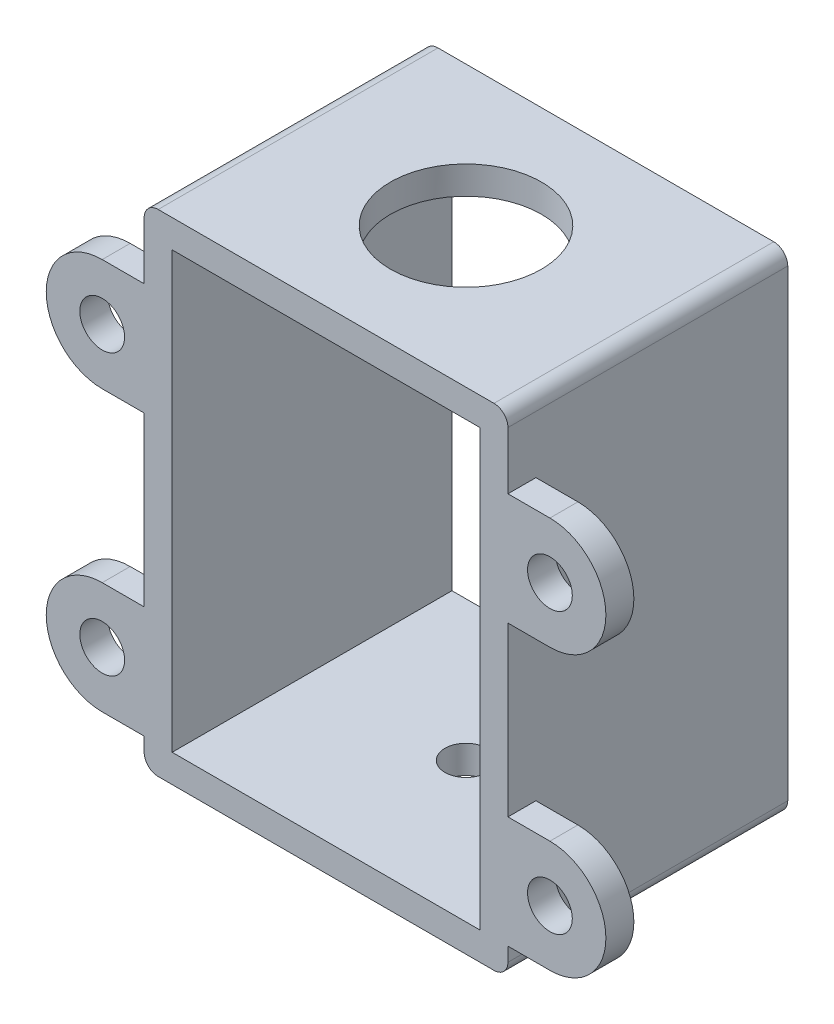
from build123d import *

# Parameters (mm, degrees)
SKETCH1_W           = 22
SKETCH1_H           = 31.5
BOSS_EXTRUDE1_DEPTH = 20
SKETCH2_R           = 5.4
CUT_EXTRUDE1_DEPTH  = 20
SKETCH3_R           = 1.5
CUT_EXTRUDE2_DEPTH  = 20
SKETCH4_W           = 22
SKETCH4_H           = 20
SKETCH4_R           = 1.5
BOSS_EXTRUDE2_DEPTH = 0.4
SKETCH5_R           = 44.087047381
CUT_EXTRUDE3_DEPTH  = 0.4
FILLET2_R           = 1
SKETCH6_R           = 1.6
BOSS_EXTRUDE3_DEPTH = 2


with BuildPart() as part:
    # Sketch1 → Boss-Extrude1 (new body)
    with BuildSketch(Plane.XY):
        Polygon((22, 2), (24, 2), (24, -33.5), (-2, -33.5), (-2, 2), align=None)
        with Locations((11, -15.75)):
            Rectangle(SKETCH1_W, SKETCH1_H, mode=Mode.SUBTRACT)
    extrude(amount=BOSS_EXTRUDE1_DEPTH)

    # Sketch2 → Cut-Extrude1 (cut)
    with BuildSketch(Plane(origin=(0, 2, 0), x_dir=(1, 0, 0), z_dir=(0, 1, 0))):
        with Locations((11, -10)):
            Circle(SKETCH2_R)
    extrude(amount=-CUT_EXTRUDE1_DEPTH, mode=Mode.SUBTRACT)

    # Sketch3 → Cut-Extrude2 (cut)
    with BuildSketch(Plane(origin=(0, -33.5, 0), x_dir=(-1, 0, 0), z_dir=(0, -1, 0))):
        with Locations((-11, -10)):
            Circle(SKETCH3_R)
    extrude(amount=-CUT_EXTRUDE2_DEPTH, mode=Mode.SUBTRACT)

    # Sketch4 → Boss-Extrude2 (add)
    with BuildSketch(Plane(origin=(0, -31.5, 0), x_dir=(1, 0, 0), z_dir=(0, 1, 0))):
        with Locations((11, -10)):
            Rectangle(SKETCH4_W, SKETCH4_H)
        with Locations((11, -10)):
            Circle(SKETCH4_R, mode=Mode.SUBTRACT)
    extrude(amount=BOSS_EXTRUDE2_DEPTH)

    # Sketch5 → Cut-Extrude3 (cut)
    with BuildSketch(Plane(origin=(0, -33.5, 0), x_dir=(-1, 0, 0), z_dir=(0, -1, 0))):
        with Locations((-11, -10)):
            Circle(SKETCH5_R)
    extrude(amount=-CUT_EXTRUDE3_DEPTH, mode=Mode.SUBTRACT)

    # Fillet2
    fillet2_edges = [part.edges().sort_by_distance(p)[0] for p in [
        (24, -33.1, 10),
        (-2, -33.1, 10),
        (-2, 2, 10),
        (24, 2, 10),
    ]]
    fillet(fillet2_edges, radius=FILLET2_R)

    # Sketch6 → Boss-Extrude3 (add)
    with BuildSketch(Plane.XY.offset(20)):
        with BuildLine():
            Line((22, -31.1), (27, -31.1))
            ThreePointArc((27, -31.1), (31, -27.1), (27, -23.1))
            Line((27, -23.1), (22, -23.1))
            Line((22, -23.1), (22, -31.1))
        make_face()
        with Locations((27, -27.1)):
            Circle(SKETCH6_R, mode=Mode.SUBTRACT)
        with BuildLine():
            Line((27, -11.1), (22, -11.1))
            Line((22, -11.1), (22, -3.1))
            Line((22, -3.1), (27, -3.1))
            ThreePointArc((27, -3.1), (31, -7.1), (27, -11.1))
        make_face()
        with Locations((27, -7.1)):
            Circle(SKETCH6_R, mode=Mode.SUBTRACT)
        with BuildLine():
            Line((0, -3.1), (-5, -3.1))
            ThreePointArc((-5, -3.1), (-9, -7.1), (-5, -11.1))
            Line((-5, -11.1), (0, -11.1))
            Line((0, -11.1), (0, -3.1))
        make_face()
        with Locations((-5, -7.1)):
            Circle(SKETCH6_R, mode=Mode.SUBTRACT)
        with BuildLine():
            Line((0, -23.1), (0, -31.1))
            Line((0, -31.1), (-5, -31.1))
            ThreePointArc((-5, -31.1), (-9, -27.1), (-5, -23.1))
            Line((-5, -23.1), (0, -23.1))
        make_face()
        with Locations((-5, -27.1)):
            Circle(SKETCH6_R, mode=Mode.SUBTRACT)
    extrude(amount=-BOSS_EXTRUDE3_DEPTH)


solid = part.part
